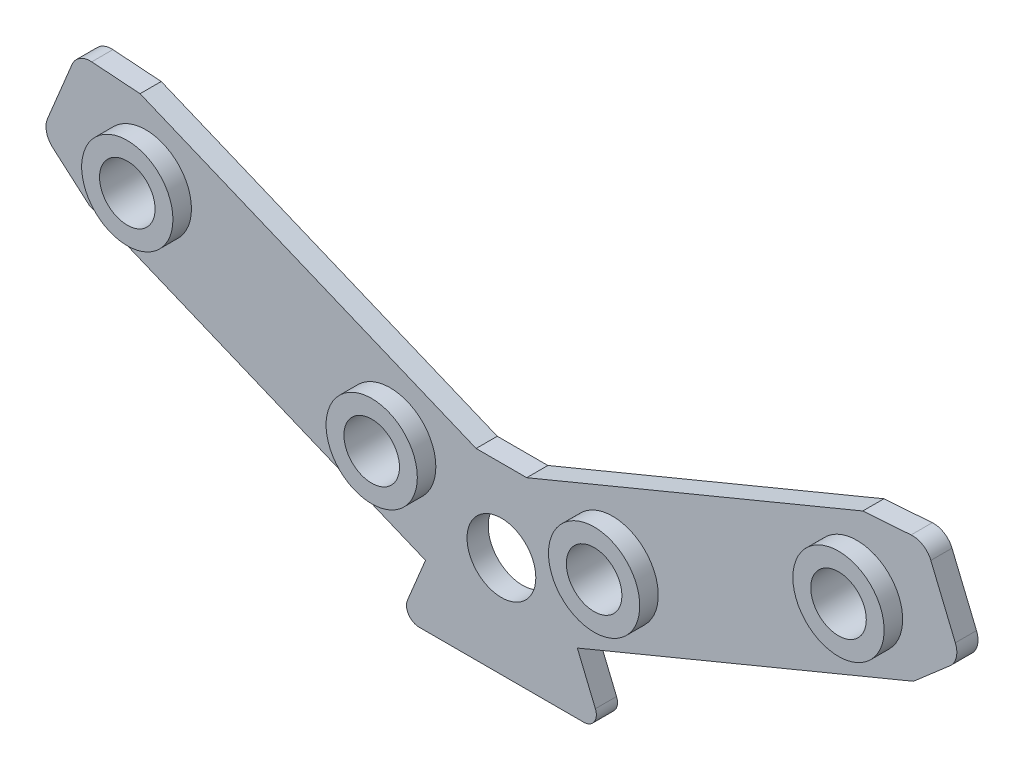
from build123d import *

# Parameters (mm, degrees)
SKETCH1_R             = 2.6
BOSS_EXTRUDE1_DEPTH   = 1.6
SKETCH2_R             = 3.45
BOSS_EXTRUDE2_DEPTH   = 1.4
M5X0_8_TAPPED_HOLE1_D = 4.2


with BuildPart() as part:
    # Sketch1 → Boss-Extrude1 (new body)
    with BuildSketch(Plane.XY):
        with BuildLine():
            Line((-1.9135, 6.204558653), (1.9135, 6.204558653))
            Line((1.9135, 6.204558653), (27.320187144, 16.728353043))
            Line((27.320187144, 16.728353043), (30.973251278, 16.987968318))
            ThreePointArc((30.973251278, 16.987968318), (31.868181477, 16.767718217), (32.465404107, 16.065767153))
            Line((32.465404107, 16.065767153), (34.316720297, 11.596294499))
            ThreePointArc((34.316720297, 11.596294499), (34.390774483, 10.67763997), (33.91370361, 9.889088418))
            Line((33.91370361, 9.889088418), (31.147021468, 7.489557718))
            Line((31.147021468, 7.489557718), (5.740334324, -3.034236672))
            Line((5.740334324, -3.034236672), (7.103934305, -6.32625824))
            ThreePointArc((7.103934305, -6.32625824), (7.015220781, -7.226981758), (6.217009953, -7.653634335))
            Line((6.217009953, -7.653634335), (-6.217009953, -7.653634335))
            ThreePointArc((-6.217009953, -7.653634335), (-7.015220781, -7.226981758), (-7.103934305, -6.32625824))
            Line((-7.103934305, -6.32625824), (-5.740334324, -3.034236672))
            Line((-5.740334324, -3.034236672), (-31.147021468, 7.489557718))
            Line((-31.147021468, 7.489557718), (-33.91370361, 9.889088418))
            ThreePointArc((-33.91370361, 9.889088418), (-34.390774483, 10.67763997), (-34.316720297, 11.596294499))
            Line((-34.316720297, 11.596294499), (-32.465404107, 16.065767153))
            ThreePointArc((-32.465404107, 16.065767153), (-31.868181477, 16.767718217), (-30.973251278, 16.987968318))
            Line((-30.973251278, 16.987968318), (-27.320187144, 16.728353043))
            Line((-27.320187144, 16.728353043), (-1.9135, 6.204558653))
        make_face()
        Circle(SKETCH1_R, mode=Mode.SUBTRACT)
    extrude(amount=BOSS_EXTRUDE1_DEPTH)

    # Sketch2 → Boss-Extrude2 (add)
    with BuildSketch(Plane.XY.offset(1.6)):
        with Locations((26.884894396, 11.136087882)):
            Circle(SKETCH2_R)
        with Locations((8.407303746, 3.482419235)):
            Circle(SKETCH2_R)
        with Locations((-8.407303746, 3.482419235)):
            Circle(SKETCH2_R)
        with Locations((-26.884894396, 11.136087882)):
            Circle(SKETCH2_R)
    extrude(amount=BOSS_EXTRUDE2_DEPTH)

    # M5x0.8 Tapped Hole1 (through all)
    with Locations(Plane.XY.offset(3)):
        with Locations((26.884894396, 11.136087882), (8.407303746, 3.482419235), (-8.407303746, 3.482419235), (-26.884894396, 11.136087882)):
            Hole(M5X0_8_TAPPED_HOLE1_D / 2)


solid = part.part
